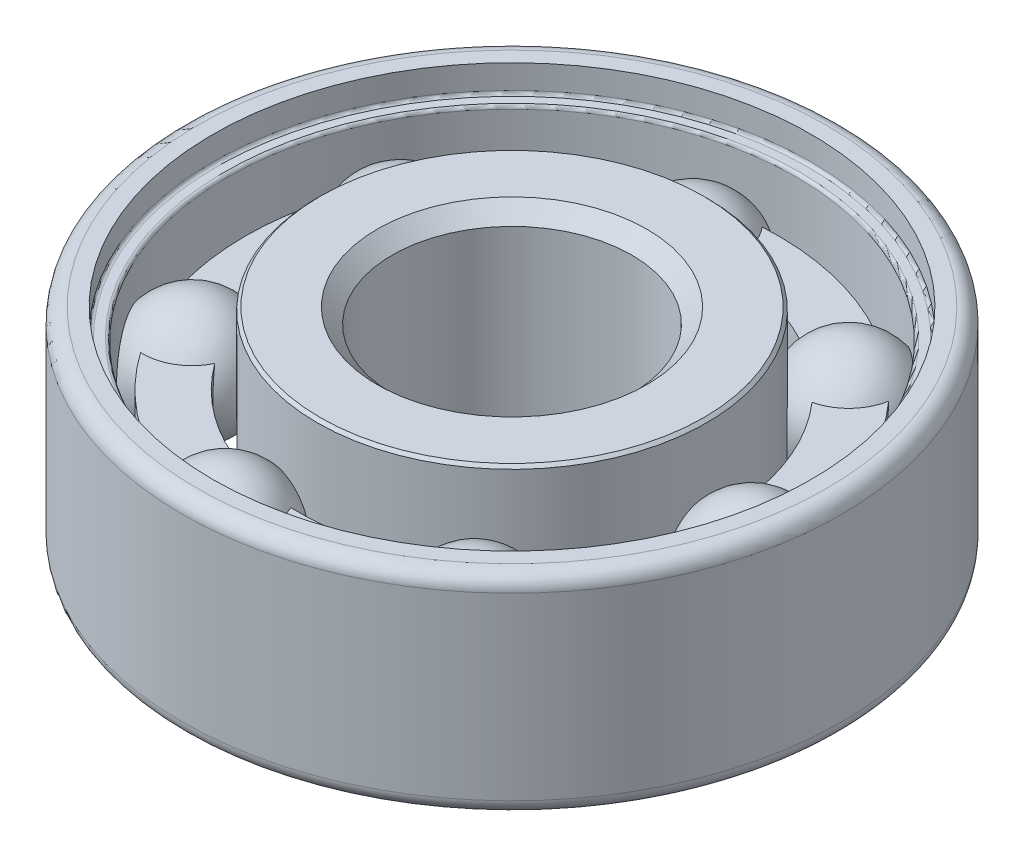
from build123d import *

# Parameters (mm, degrees)
FILLET2_R          = 0.1
FILLET5_R          = 0.5
CHAMFER1_SIZE      = 0.5
CHAMFER2_SIZE      = 0.1
SKETCH10_R         = 9.5
SKETCH10_R_2       = 8.9
CUT_EXTRUDE3_DEPTH = 5.6
SKETCH12_R         = 7.1
SKETCH12_R_2       = 6.5
CUT_EXTRUDE4_DEPTH = 5.6
CIRPATTERN2_COUNT  = 7


with BuildPart() as part:
    # Sketch3 → Revolve1 (revolve)
    with BuildSketch(Plane.XY):
        Polygon((4, -3.5), (4, 3.5), (6.5, 3.5), (6.5, 1.1), (9.5, 1.1), (9.5, 2.6), (9.982831226, 2.6), (9.982831226, 3.5), (11, 3.5), (11, -3.5), (9.982831226, -3.5), (9.982831226, -2.6), (9.5, -2.6), (9.5, -1.1), (6.5, -1.1), (6.5, -3.5), align=None)
    revolve(axis=Axis((0, 3.5, 0), (0, -1, 0)))

    # Fillet2
    fillet2_edges = [part.edges().sort_by_distance(p)[0] for p in [
        (-9.5, -2.6, 0),
        (-9.982831226, -2.6, 0),
        (-9.982831226, 2.6, 0),
        (-9.5, 2.6, 0),
    ]]
    fillet(fillet2_edges, radius=FILLET2_R)

    # Fillet5
    fillet5_edges = [part.edges().sort_by_distance(p)[0] for p in [
        (-11, -3.5, 0),
        (-11, 3.5, 0),
    ]]
    fillet(fillet5_edges, radius=FILLET5_R)

    # Chamfer1
    chamfer1_edges = [part.edges().sort_by_distance(p)[0] for p in [
        (-4, 3.5, 0),
        (-4, -3.5, 0),
    ]]
    chamfer(chamfer1_edges, length=CHAMFER1_SIZE)

    # Chamfer2
    chamfer2_edges = [part.edges().sort_by_distance(p)[0] for p in [
        (-6.5, -3.5, 0),
        (-6.5, 3.5, 0),
    ]]
    chamfer(chamfer2_edges, length=CHAMFER2_SIZE)

    # Sketch10 → Cut-Extrude3 (cut, through all)
    with BuildSketch(Plane.XZ.offset(1.1)):
        Circle(SKETCH10_R)
        Circle(SKETCH10_R_2, mode=Mode.SUBTRACT)
    extrude(amount=-CUT_EXTRUDE3_DEPTH, mode=Mode.SUBTRACT)

    # Sketch12 → Cut-Extrude4 (cut, through all)
    with BuildSketch(Plane.XZ.offset(1.1)):
        Circle(SKETCH12_R)
        Circle(SKETCH12_R_2, mode=Mode.SUBTRACT)
    extrude(amount=-CUT_EXTRUDE4_DEPTH, mode=Mode.SUBTRACT)

    # Sketch6 → Revolve7 (revolve)
    with BuildSketch(Plane.XY):
        with BuildLine():
            ThreePointArc((9.982831226, 0), (8, 1.982831226), (6.017168774, 0))
            Line((6.017168774, 0), (9.982831226, 0))
        make_face()
    revolve7 = revolve(axis=Axis((0, 0, 0), (1, 0, 0)))

    # CirPattern2: Revolve7 ×7 about axis
    cirpattern2_axis = Axis((0, 0, 0), (0, 1, 0))
    for i in range(1, CIRPATTERN2_COUNT):
        add(revolve7.rotate(cirpattern2_axis, i * 360 / CIRPATTERN2_COUNT))


solid = part.part
